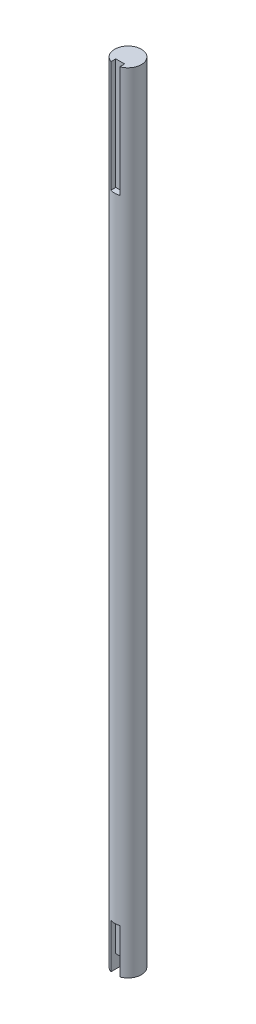
from build123d import *

# Parameters (mm, degrees)
SKETCH1_R                = 6
BOSS_EXTRUDE1_DEPTH      = 254
BOSS_EXTRUDE1_DEPTH_BACK = 100
CUT_EXTRUDE3_START       = -100
SKETCH2_W                = 4
SKETCH2_H                = 5
CUT_EXTRUDE3_DEPTH       = 20
CUT_EXTRUDE3_DEPTH_BACK  = 0.0001
CUT_EXTRUDE4_START       = 254
SKETCH2_2_W              = 4
SKETCH2_2_H              = 5
CUT_EXTRUDE4_DEPTH       = 50
CUT_EXTRUDE6_START       = -100
SKETCH3_W                = 4
SKETCH3_H                = 10
CUT_EXTRUDE6_DEPTH       = 6


with BuildPart() as part:
    # Sketch1 → Boss-Extrude1 (new body, two sides)
    with BuildSketch(Plane(origin=(0, 0, 0), x_dir=(1, 0, 0), z_dir=(0, 1, 0))) as boss_extrude1_sk:
        Circle(SKETCH1_R)
    extrude(amount=BOSS_EXTRUDE1_DEPTH)
    extrude(boss_extrude1_sk.sketch, amount=-BOSS_EXTRUDE1_DEPTH_BACK)

    # Sketch2 → Cut-Extrude3 (cut, two sides)
    with BuildSketch(Plane(origin=(0, 0, 0), x_dir=(1, 0, 0), z_dir=(0, 1, 0)).offset(CUT_EXTRUDE3_START)) as cut_extrude3_sk:
        with Locations((0, -6)):
            Rectangle(SKETCH2_W, SKETCH2_H)
    extrude(amount=CUT_EXTRUDE3_DEPTH, mode=Mode.SUBTRACT)
    extrude(cut_extrude3_sk.sketch, amount=-CUT_EXTRUDE3_DEPTH_BACK, mode=Mode.SUBTRACT)

    # Sketch2_2 → Cut-Extrude4 (cut)
    with BuildSketch(Plane(origin=(0, 0, 0), x_dir=(1, 0, 0), z_dir=(0, 1, 0)).offset(CUT_EXTRUDE4_START)):
        with Locations((0, -6)):
            Rectangle(SKETCH2_2_W, SKETCH2_2_H)
    extrude(amount=-CUT_EXTRUDE4_DEPTH, mode=Mode.SUBTRACT)

    # Sketch3 → Cut-Extrude6 (cut)
    with BuildSketch(Plane(origin=(0, 0, 0), x_dir=(1, 0, 0), z_dir=(0, 1, 0)).offset(CUT_EXTRUDE6_START)):
        with Locations((0, -6)):
            Rectangle(SKETCH3_W, SKETCH3_H)
    extrude(amount=CUT_EXTRUDE6_DEPTH, mode=Mode.SUBTRACT)


solid = part.part
